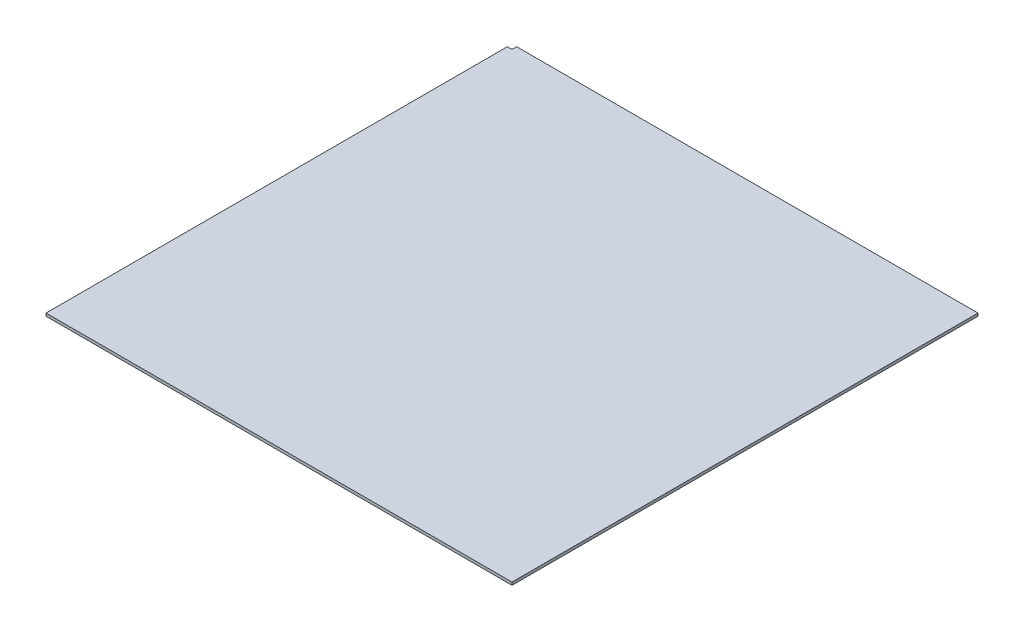
from build123d import *

# Parameters (mm, degrees)
RESSALTO_EXTRUS_O1_DEPTH = 3


with BuildPart() as part:
    # Esboço1 → Ressalto-extrusão1 (new body, symmetric)
    with BuildSketch(Plane(origin=(0, 0, 0), x_dir=(1, 0, 0), z_dir=(0, 1, 0))):
        Polygon((-490, 500), (500, 500), (500, -500), (-500, -500), (-500, 490), (-490, 490), align=None)
    extrude(amount=RESSALTO_EXTRUS_O1_DEPTH, both=True)


solid = part.part
